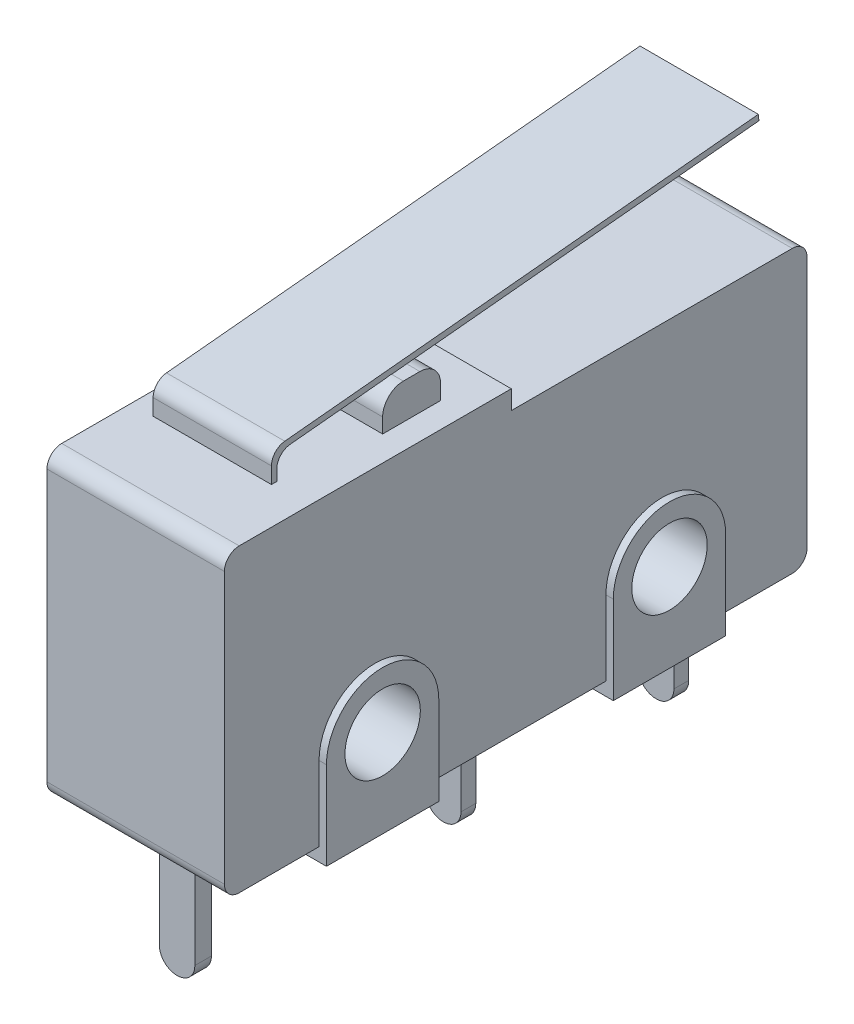
from build123d import *

# Parameters (mm, degrees)
SKETCH1_R           = 1.275
BOSS_EXTRUDE1_DEPTH = 6.5
SKETCH2_W           = 3.53
SKETCH2_H           = 1.96
BOSS_EXTRUDE2_DEPTH = 1.2
FILLET1_R           = 0.7
SKETCH3_W           = 3.2
SKETCH3_H           = 0.56
SKETCH3_H_2         = 0.5
BOSS_EXTRUDE3_DEPTH = 0.9
SKETCH4_W           = 1.2
SKETCH4_H           = 0.56
SKETCH4_H_2         = 0.5
BOSS_EXTRUDE4_DEPTH = 3.47
FILLET2_R           = 0.59
EXTRUDE_START       = -1.5
EXTRUDE_1_DEPTH     = 4
FILLET_1_R          = 0.5
EXTRUDE1_DEPTH      = 0.25
EXTRUDE2_START      = -6.5
EXTRUDE2_DEPTH      = 0.25


with BuildPart() as part:
    # Sketch1 → Boss-Extrude1 (new body)
    with BuildSketch(Plane(origin=(0, 0, 0), x_dir=(0, 0, -1), z_dir=(1, 0, 0))):
        with BuildLine():
            Line((-37.373122581, 0), (-34.673122581, 0))
            Line((-34.673122581, 0), (-34.673122581, -0.45))
            Line((-34.673122581, -0.45), (-30.873122581, -0.45))
            Line((-30.873122581, -0.45), (-30.873122581, 0))
            Line((-30.873122581, 0), (-24.973122581, 0))
            Line((-24.973122581, 0), (-24.973122581, -0.45))
            Line((-24.973122581, -0.45), (-21.173122581, -0.45))
            Line((-21.173122581, -0.45), (-21.173122581, 0))
            Line((-21.173122581, 0), (-18.673122581, 0))
            ThreePointArc((-18.673122581, 0), (-18.31956919, 0.146446609), (-18.173122581, 0.5))
            Line((-18.173122581, 0.5), (-18.173122581, 9.02))
            ThreePointArc((-18.173122581, 9.02), (-18.31956919, 9.373553391), (-18.673122581, 9.52))
            Line((-18.673122581, 9.52), (-28.173122581, 9.52))
            Line((-28.173122581, 9.52), (-28.173122581, 10.16))
            Line((-28.173122581, 10.16), (-37.373122581, 10.16))
            ThreePointArc((-37.373122581, 10.16), (-37.726675972, 10.013553391), (-37.873122581, 9.66))
            Line((-37.873122581, 9.66), (-37.873122581, 0.5))
            ThreePointArc((-37.873122581, 0.5), (-37.726675972, 0.146446609), (-37.373122581, 0))
        make_face()
        with Locations((-32.773122581, 2.525)):
            Circle(SKETCH1_R, mode=Mode.SUBTRACT)
        with Locations((-23.073122581, 2.525)):
            Circle(SKETCH1_R, mode=Mode.SUBTRACT)
    extrude(amount=BOSS_EXTRUDE1_DEPTH)

    # Sketch2 → Boss-Extrude2 (add)
    with BuildSketch(Plane(origin=(0, 10.16, 0), x_dir=(1, 0, 0), z_dir=(0, 1, 0))):
        with Locations((3.635, -30.693122581)):
            Rectangle(SKETCH2_W, SKETCH2_H)
    extrude(amount=BOSS_EXTRUDE2_DEPTH)

    # Fillet1
    fillet1_edges = [part.edges().sort_by_distance(p)[0] for p in [
        (3.635, 11.36, 31.673122581),
        (3.635, 11.36, 29.713122581),
    ]]
    fillet(fillet1_edges, radius=FILLET1_R)

    # Sketch3 → Boss-Extrude3 (add)
    with BuildSketch(Plane(origin=(0, 0, 0), x_dir=(-1, 0, 0), z_dir=(0, -1, 0))):
        with Locations((-3.25, -36.193122581)):
            Rectangle(SKETCH3_W, SKETCH3_H)
        with Locations((-3.25, -27.223122581)):
            Rectangle(SKETCH3_W, SKETCH3_H_2)
        with Locations((-3.25, -20.023122581)):
            Rectangle(SKETCH3_W, SKETCH3_H_2)
    extrude(amount=BOSS_EXTRUDE3_DEPTH)

    # Sketch4 → Boss-Extrude4 (add)
    with BuildSketch(Plane(origin=(0, -0.9, 0), x_dir=(-1, 0, 0), z_dir=(0, -1, 0))):
        with Locations((-3.25, -36.193122581)):
            Rectangle(SKETCH4_W, SKETCH4_H)
        with Locations((-3.25, -27.223122581)):
            Rectangle(SKETCH4_W, SKETCH4_H_2)
        with Locations((-3.25, -20.023122581)):
            Rectangle(SKETCH4_W, SKETCH4_H_2)
    extrude(amount=BOSS_EXTRUDE4_DEPTH)

    # Fillet2
    fillet2_edges = [part.edges().sort_by_distance(p)[0] for p in [
        (2.65, -4.37, 36.193122581),
        (3.85, -4.37, 36.193122581),
        (2.65, -4.37, 27.223122581),
        (3.85, -4.37, 27.223122581),
        (3.85, -4.37, 20.023122581),
        (2.65, -4.37, 20.023122581),
    ]]
    fillet(fillet2_edges, radius=FILLET2_R)

    # Эскиз1 → Бобышка-Вытянуть1 (add)
    with BuildSketch(Plane(origin=(6.5, 0, 0), x_dir=(0, 0, -1), z_dir=(1, 0, 0)).offset(EXTRUDE_START)):
        Polygon((-34.851945428, 10.16), (-34.851945428, 10.976764044), (-18.550578779, 12.570949573), (-18.570044834, 12.77), (-35.033122581, 11.16), (-35.033122581, 10.16), align=None)
    extrude(amount=-EXTRUDE_1_DEPTH)

    # Скругление1
    fillet_1_edges = [part.edges().sort_by_distance(p)[0] for p in [
        (3, 11.16, 35.033122581),
        (3, 10.976764044, 34.851945428),
    ]]
    fillet(fillet_1_edges, radius=FILLET_1_R)

    # Sketch6 → Extrude1 (cut)
    with BuildSketch(Plane(origin=(6.5, 0, 0), x_dir=(0, 0, -1), z_dir=(1, 0, 0))):
        with BuildLine():
            Line((-34.673122581, 0), (-34.673122581, 2.525))
            ThreePointArc((-34.673122581, 2.525), (-32.773122581, 4.425), (-30.873122581, 2.525))
            Line((-30.873122581, 2.525), (-30.873122581, 0))
            Line((-30.873122581, 0), (-24.973122581, 0))
            Line((-24.973122581, 0), (-24.973122581, 2.525))
            ThreePointArc((-24.973122581, 2.525), (-23.073122581, 4.425), (-21.173122581, 2.525))
            Line((-21.173122581, 2.525), (-21.173122581, 0))
            Line((-21.173122581, 0), (-18.673122581, 0))
            ThreePointArc((-18.673122581, 0), (-18.31956919, 0.146446609), (-18.173122581, 0.5))
            Line((-18.173122581, 0.5), (-18.173122581, 9.02))
            ThreePointArc((-18.173122581, 9.02), (-18.31956919, 9.373553391), (-18.673122581, 9.52))
            Line((-18.673122581, 9.52), (-28.173122581, 9.52))
            Line((-28.173122581, 9.52), (-28.173122581, 10.16))
            Line((-28.173122581, 10.16), (-37.373122581, 10.16))
            ThreePointArc((-37.373122581, 10.16), (-37.726675972, 10.013553391), (-37.873122581, 9.66))
            Line((-37.873122581, 9.66), (-37.873122581, 0.5))
            ThreePointArc((-37.873122581, 0.5), (-37.726675972, 0.146446609), (-37.373122581, 0))
            Line((-37.373122581, 0), (-34.673122581, 0))
        make_face()
    extrude(amount=-EXTRUDE1_DEPTH, mode=Mode.SUBTRACT)

    # Sketch → Extrude2 (cut)
    with BuildSketch(Plane(origin=(6.5, 0, 0), x_dir=(0, 0, -1), z_dir=(1, 0, 0)).offset(EXTRUDE2_START)):
        with BuildLine():
            Line((-34.673122581, 0), (-34.673122581, 2.525))
            ThreePointArc((-34.673122581, 2.525), (-32.773122581, 4.425), (-30.873122581, 2.525))
            Line((-30.873122581, 2.525), (-30.873122581, 0))
            Line((-30.873122581, 0), (-24.973122581, 0))
            Line((-24.973122581, 0), (-24.973122581, 2.525))
            ThreePointArc((-24.973122581, 2.525), (-23.073122581, 4.425), (-21.173122581, 2.525))
            Line((-21.173122581, 2.525), (-21.173122581, 0))
            Line((-21.173122581, 0), (-18.673122581, 0))
            ThreePointArc((-18.673122581, 0), (-18.31956919, 0.146446609), (-18.173122581, 0.5))
            Line((-18.173122581, 0.5), (-18.173122581, 9.02))
            ThreePointArc((-18.173122581, 9.02), (-18.31956919, 9.373553391), (-18.673122581, 9.52))
            Line((-18.673122581, 9.52), (-28.173122581, 9.52))
            Line((-28.173122581, 9.52), (-28.173122581, 10.16))
            Line((-28.173122581, 10.16), (-37.373122581, 10.16))
            ThreePointArc((-37.373122581, 10.16), (-37.726675972, 10.013553391), (-37.873122581, 9.66))
            Line((-37.873122581, 9.66), (-37.873122581, 0.5))
            ThreePointArc((-37.873122581, 0.5), (-37.726675972, 0.146446609), (-37.373122581, 0))
            Line((-37.373122581, 0), (-34.673122581, 0))
        make_face()
    extrude(amount=EXTRUDE2_DEPTH, mode=Mode.SUBTRACT)


solid = part.part
